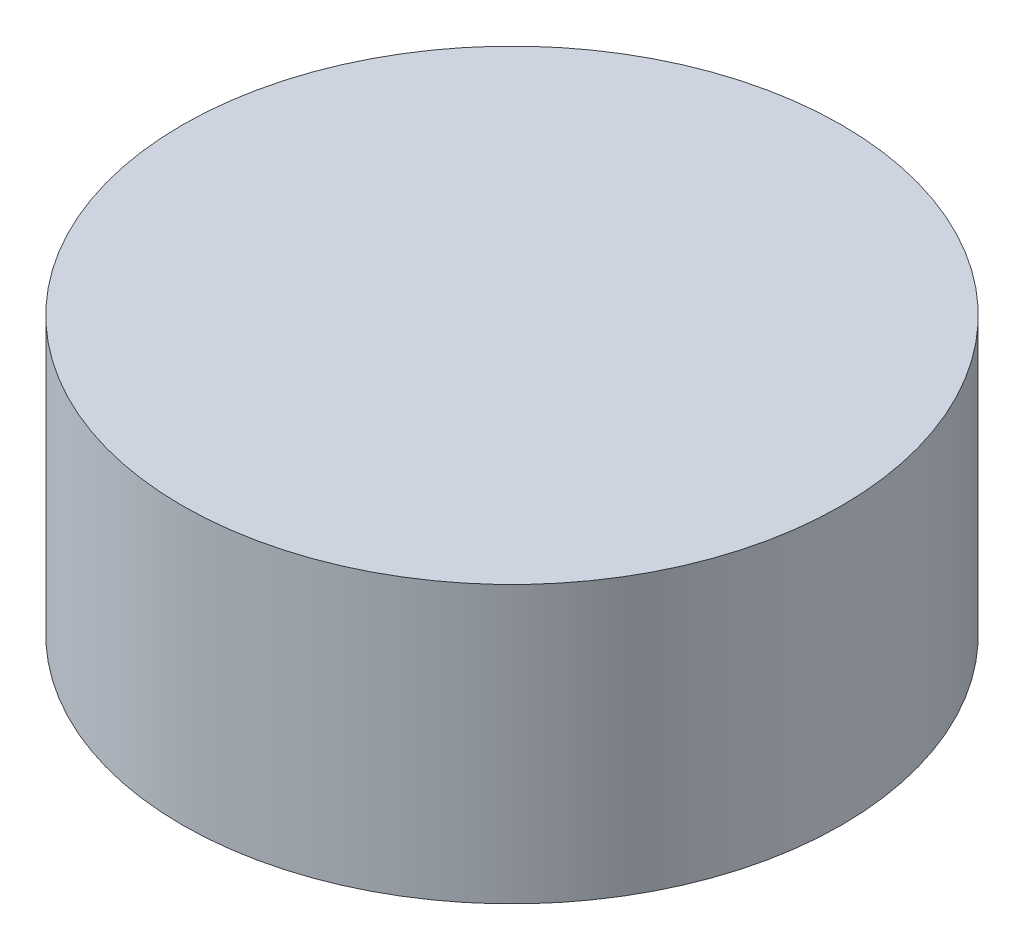
from build123d import *

# Parameters (mm, degrees)
SKETCH3_W = 3250
SKETCH3_H = 3000


with BuildPart() as part:
    # Sketch2 → Revolve2 (revolve)
    with BuildSketch(Plane.XY):
        Polygon((-2765, 500), (-7000, 500), (-7000, 3372), (0, 3372), (0, 3342), (-2133.6, 3342), (-2765, 2735.874225372), align=None)
    revolve(axis=Axis((0, 3520.44, 0), (0, -1, 0)))

    # Sketch3 → Revolve3 (revolve)
    with BuildSketch(Plane(origin=(0, 0, 0), x_dir=(0, 0, -1), z_dir=(1, 0, 0))):
        with Locations((-5375, -1000)):
            Rectangle(SKETCH3_W, SKETCH3_H)
    revolve(axis=Axis((0, 3520.44, 0), (0, -1, 0)))


solid = part.part
